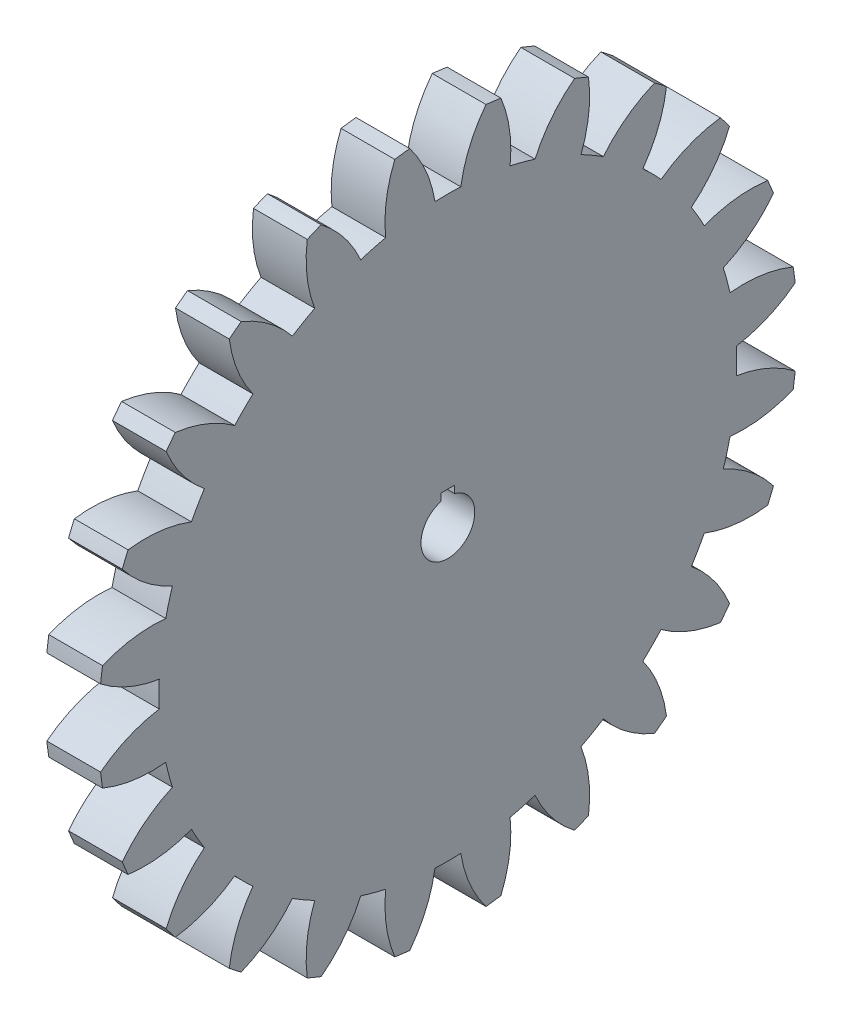
from build123d import *

# Parameters (mm, degrees)
BASPROSKE_W     = 12.7
BASPROSKE_H     = 82.55
TOOTHCUT_DEPTH  = 118.432086757
TEETHCUTS_COUNT = 24
TEETHCUTS_ANGLE = 345
BORSKE_R        = 6.35
BORE_DEPTH      = 50.8000508
KEYSKE_W        = 3.175
KEYSKE_H        = 7.874
KEYWAY_DEPTH    = 50.8000508


with BuildPart() as part:
    # BasProSke → Base-Revolve (revolve)
    with BuildSketch(Plane(origin=(0, 0, 0), x_dir=(1, 0, 0), z_dir=(0, 1, 0)), mode=Mode.PRIVATE) as base_revolve_sk:
        with Locations((6.35, 41.275)):
            Rectangle(BASPROSKE_W, BASPROSKE_H)
    revolve(base_revolve_sk.sketch.rotate(Axis((-10, 0, 0), (1, 0, 0)), 180), axis=Axis((-10, 0, 0), (1, 0, 0)))

    # TooCutSke → ToothCut (cut, through all)
    with BuildSketch(Plane(origin=(0, 0, 0), x_dir=(0, 0, -1), z_dir=(1, 0, 0))):
        with BuildLine():
            ThreePointArc((3.050766134, 68.193022716), (0, 68.26123), (-3.050766134, 68.193022716))
            ThreePointArc((-3.050766134, 68.193022716), (-5.164725154, 75.513208068), (-9.02816666, 82.080380676))
            ThreePointArc((-9.02816666, 82.080380676), (0, 82.5754), (9.02816666, 82.080380676))
            ThreePointArc((9.02816666, 82.080380676), (5.164725154, 75.513208068), (3.050766134, 68.193022716))
        make_face()
    toothcut = extrude(amount=TOOTHCUT_DEPTH, mode=Mode.SUBTRACT)

    # TeethCuts: ToothCut ×24 about axis
    teethcuts_axis = Axis((-10, 0, 0), (1, 0, 0))
    for i in range(1, TEETHCUTS_COUNT):
        add(toothcut.rotate(teethcuts_axis, i * TEETHCUTS_ANGLE / (TEETHCUTS_COUNT - 1)), mode=Mode.SUBTRACT)

    # BorSke → Bore (cut, symmetric)
    with BuildSketch(Plane(origin=(0, 0, 0), x_dir=(0, 0, -1), z_dir=(1, 0, 0))):
        with Locations(Location((0, 0, 0), (0, 0, 180))):
            Circle(BORSKE_R)
    extrude(amount=BORE_DEPTH, both=True, mode=Mode.SUBTRACT)

    # KeySke → Keyway (cut, symmetric)
    with BuildSketch(Plane(origin=(0, 0, 0), x_dir=(0, 0, -1), z_dir=(1, 0, 0))):
        with Locations((0, 3.937)):
            Rectangle(KEYSKE_W, KEYSKE_H)
    extrude(amount=KEYWAY_DEPTH, both=True, mode=Mode.SUBTRACT)


solid = part.part
